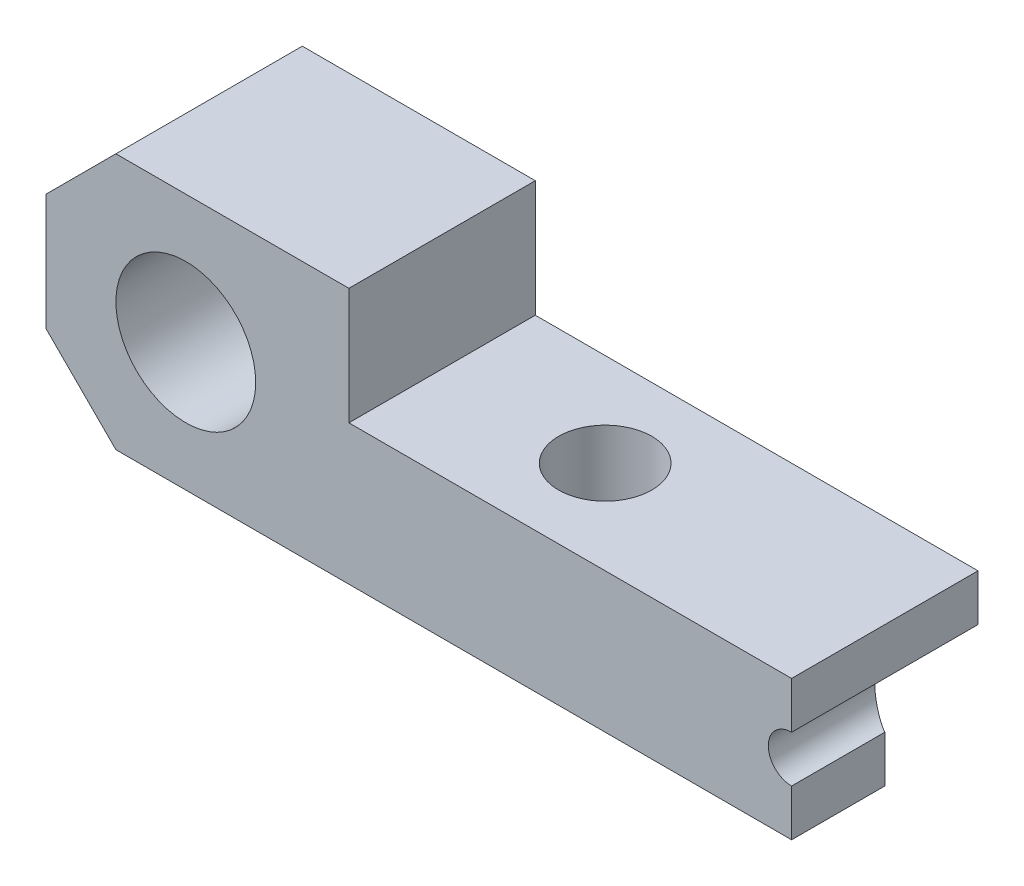
from build123d import *

# Parameters (mm, degrees)
ESQUISSE1_R             = 3
EXTRUSION1_DEPTH        = 8
ESQUISSE2_R             = 1
ENL_V_MAT_EXTRU_1_DEPTH = 9
ENL_V_MAT_EXTRU_4_DEPTH = 4
ESQUISSE4_R             = 2
ENL_V_MAT_EXTRU_5_DEPTH = 12
CHANFREIN1_SIZE         = 3


with BuildPart() as part:
    # Esquisse1 → Extrusion1 (new body)
    with BuildSketch(Plane.XY):
        Polygon((32, 6), (13, 6), (13, 11), (0, 11), (0, 0), (32, 0), align=None)
        with Locations((6, 5.5)):
            Circle(ESQUISSE1_R, mode=Mode.SUBTRACT)
    extrude(amount=EXTRUSION1_DEPTH)

    # Esquisse2 → Enlèv. mat.-Extru.1 (cut, through all)
    with BuildSketch(Plane.XY.offset(8)):
        with Locations((32, 3)):
            Circle(ESQUISSE2_R)
    extrude(amount=-ENL_V_MAT_EXTRU_1_DEPTH, mode=Mode.SUBTRACT)

    # Esquisse3 → Enlèv. mat.-Extru.4 (cut)
    with BuildSketch(Plane.XZ):
        Polygon((25, 0), (32, 4), (32, 0), align=None)
    extrude(amount=-ENL_V_MAT_EXTRU_4_DEPTH, mode=Mode.SUBTRACT)

    # Esquisse4 → Enlèv. mat.-Extru.5 (cut, through all)
    with BuildSketch(Plane.XZ):
        with Locations(Location((20, 4, 0), (0, 0, 270))):  # turned: the seam where the file's is
            Circle(ESQUISSE4_R)
    extrude(amount=-ENL_V_MAT_EXTRU_5_DEPTH, mode=Mode.SUBTRACT)

    # Chanfrein1
    chanfrein1_edges = [part.edges().sort_by_distance(p)[0] for p in [
        (0, 0, 4),
        (0, 11, 4),
    ]]
    chamfer(chanfrein1_edges, length=CHANFREIN1_SIZE)


solid = part.part
